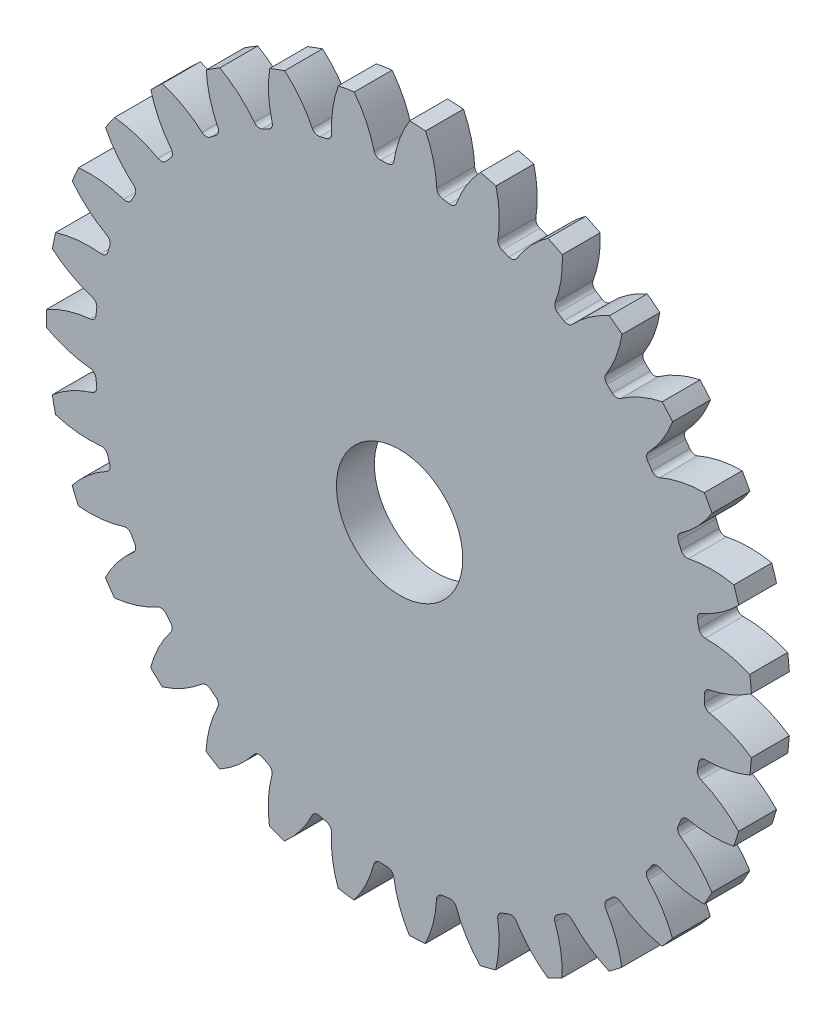
from build123d import *

# Parameters (mm, degrees)
CROQUIS1_R              = 27.94
SALIENTE_EXTRUIR1_DEPTH = 3
CORTAR_EXTRUIR1_DEPTH   = 4
REDONDEO1_R             = 0.508
MATRIZC1_COUNT          = 31
REDONDEO1_OF_MATRIZC1_R = 0.508
CROQUIS3_R              = 5
CORTAR_EXTRUIR2_DEPTH   = 4.0000001


with BuildPart() as part:
    # Croquis1 → Saliente-Extruir1 (new body)
    with BuildSketch(Plane.XY):
        Circle(CROQUIS1_R)
    extrude(amount=SALIENTE_EXTRUIR1_DEPTH)

    # Croquis2 → Cortar-Extruir1 (cut, through all)
    with BuildSketch(Plane.XY.offset(3)):
        with BuildLine():
            ThreePointArc((0.793159176, 27.928739652), (-1.403748792, 27.904714464), (-3.591976909, 27.708145046))
            ThreePointArc((-3.591976909, 27.708145046), (-2.553094505, 25.974633517), (-1.927624767, 24.052882629))
            ThreePointArc((-1.927624767, 24.052882629), (-1.212328502, 24.099526128), (-0.495962394, 24.124902514))
            ThreePointArc((-0.495962394, 24.124902514), (-0.066509893, 26.099721346), (0.793159176, 27.928739652))
        make_face()
    cortar_extruir1 = extrude(amount=-CORTAR_EXTRUIR1_DEPTH, mode=Mode.SUBTRACT)

    # Redondeo1
    redondeo1_edges = [part.edges().sort_by_distance(p)[0] for p in [
        (-0.495962394, 24.124902514, 1.5),
        (-1.927624767, 24.052882629, 1.5),
    ]]
    fillet(redondeo1_edges, radius=REDONDEO1_R)

    # MatrizC1: Cortar-Extruir1 ×31 about axis
    matrizc1_axis = Axis((0, 0, 0), (0, 0, 1))
    for i in range(1, MATRIZC1_COUNT):
        add(cortar_extruir1.rotate(matrizc1_axis, i * 360 / MATRIZC1_COUNT), mode=Mode.SUBTRACT)

    # Redondeo1 of MatrizC1
    redondeo1_of_matrizc1_edges = [part.edges().sort_by_distance(p)[0] for p in [
        (-5.342117188, 23.531227846, 1.5),
        (-6.729975852, 23.172490695, 1.5),
        (-9.969565076, 21.974181946, 1.5),
        (-11.256800935, 21.34341427, 1.5),
        (-14.188857799, 19.517510455, 1.5),
        (-15.322771265, 18.640535957, 1.5),
        (-17.827257017, 16.261789792, 1.5),
        (-18.761425539, 15.174511912, 1.5),
        (-20.735806238, 12.340309545, 1.5),
        (-21.431984847, 11.087241566, 1.5),
        (-22.795429115, 7.913615575, 1.5),
        (-23.225116177, 6.546058247, 1.5),
        (-23.921804445, 3.162937254, 1.5),
        (-24.067408522, 1.736878535, 1.5),
        (-24.068818291, -1.71723209, 1.5),
        (-23.924378334, -3.143409188, 1.5),
        (-23.230451889, -6.527097751, 1.5),
        (-22.801881287, -7.89500537, 1.5),
        (-21.441028056, -11.069743263, 1.5),
        (-20.74587254, -12.323379105, 1.5),
        (-18.773806016, -15.159192184, 1.5),
        (-17.840525334, -16.247232251, 1.5),
        (-15.337982151, -18.628021997, 1.5),
        (-14.204784925, -19.505921799, 1.5),
        (-11.274219495, -21.334218401, 1.5),
        (-9.987498952, -21.966036618, 1.5),
        (-6.748888968, -23.166989396, 1.5),
        (-5.361323598, -23.526859316, 1.5),
        (-1.947258134, -24.051301124, 1.5),
        (-0.515655026, -24.12448963, 1.5),
        (2.934093676, -23.950949758, 1.5),
        (4.351124523, -23.734460503, 1.5),
        (7.695323347, -22.870043694, 1.5),
        (9.039768522, -22.372739775, 1.5),
        (12.141505576, -20.852835355, 1.5),
        (13.358323337, -20.095076452, 1.5),
        (16.090613141, -17.981909486, 1.5),
        (17.129986824, -16.994718338, 1.5),
        (19.380969112, -14.37480213, 1.5),
        (20.200346639, -13.198594459, 1.5),
        (21.877865931, -10.179188686, 1.5),
        (22.443701888, -8.862118571, 1.5),
        (23.479080348, -5.56683806, 1.5),
        (23.768209345, -4.162826508, 1.5),
        (24.119058458, -0.726580431, 1.5),
        (24.119643519, 0.706892161, 1.5),
        (23.771599479, 4.143423486, 1.5),
        (23.483616653, 5.547670583, 1.5),
        (22.450928426, 8.84379516, 1.5),
        (21.886167762, 10.161326719, 1.5),
        (20.211113724, 13.18210082, 1.5),
        (19.392696592, 14.358976945, 1.5),
        (17.143853652, 16.980729724, 1.5),
        (16.105286144, 17.968768968, 1.5),
        (13.374722198, 20.084165557, 1.5),
        (12.15852339, 20.842917478, 1.5),
        (9.058028044, 22.365353294, 1.5),
        (7.713989259, 22.863754497, 1.5),
        (4.370497159, 23.730900838, 1.5),
        (2.953643502, 23.948546721, 1.5),
    ]]
    fillet(redondeo1_of_matrizc1_edges, radius=REDONDEO1_OF_MATRIZC1_R)

    # Croquis3 → Cortar-Extruir2 (cut, through all)
    with BuildSketch(Plane.XY.offset(3)):
        Circle(CROQUIS3_R)
    extrude(amount=-CORTAR_EXTRUIR2_DEPTH, mode=Mode.SUBTRACT)


solid = part.part
